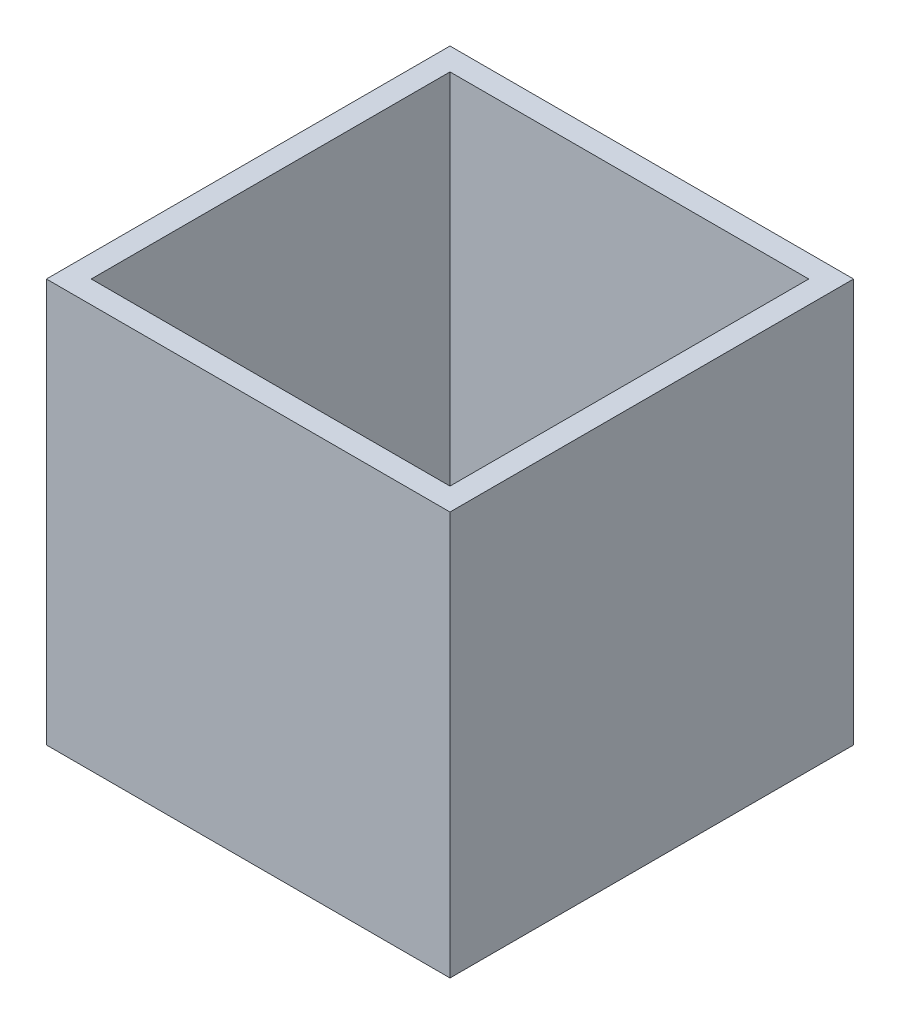
from build123d import *

# Parameters (mm, degrees)
SKETCH1_W           = 18
SKETCH1_H           = 18
BOSS_EXTRUDE1_DEPTH = 18
SHELL1_T            = -1


with BuildPart() as part:
    # Sketch1 → Boss-Extrude1 (new body)
    with BuildSketch(Plane(origin=(0, 0, 0), x_dir=(1, 0, 0), z_dir=(0, 1, 0))):
        Rectangle(SKETCH1_W, SKETCH1_H)
    extrude(amount=BOSS_EXTRUDE1_DEPTH)

    # Shell1
    shell1_openings = [part.faces().sort_by_distance(p)[0] for p in [
        (0, 18, 0),
    ]]
    offset(amount=SHELL1_T, openings=shell1_openings, kind=Kind.INTERSECTION)


solid = part.part
